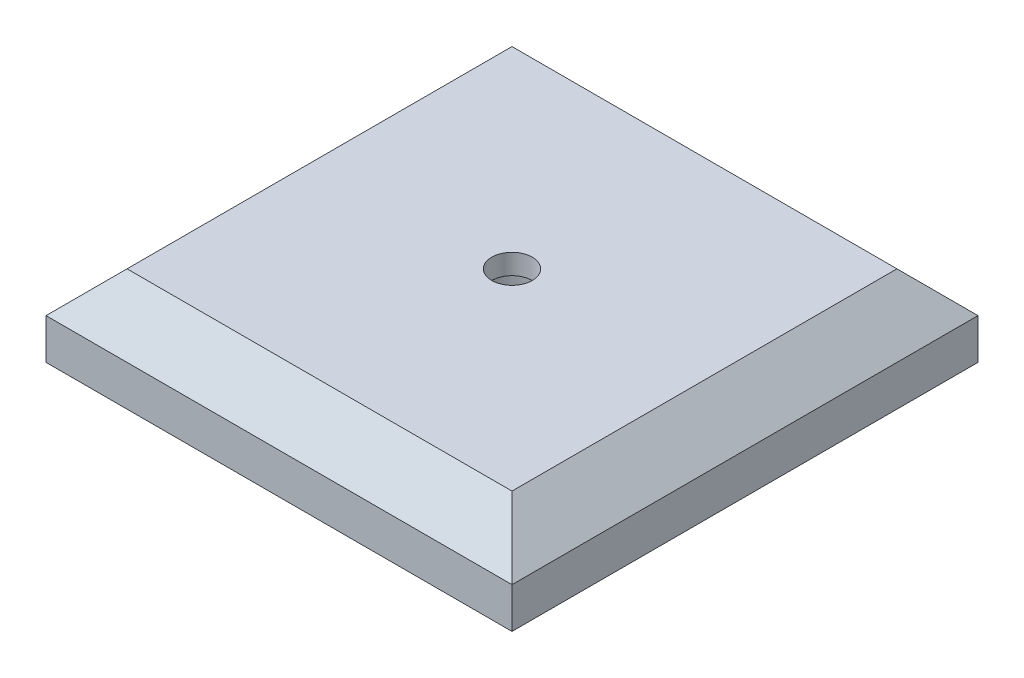
from build123d import *

# Parameters (mm, degrees)
SKETCH2_W           = 28.75
SKETCH2_H           = 28.75
BOSS_EXTRUDE1_DEPTH = 5
CHAMFER1_SIZE       = 2.5
SKETCH3_R           = 1.25
CUT_EXTRUDE1_DEPTH  = 1.25
SKETCH6_R           = 2.5
CUT_EXTRUDE2_DEPTH  = 3.75


with BuildPart() as part:
    # Sketch2 → Boss-Extrude1 (new body)
    with BuildSketch(Plane(origin=(0, 0, 0), x_dir=(1, 0, 0), z_dir=(0, 1, 0))):
        Rectangle(SKETCH2_W, SKETCH2_H)
    extrude(amount=BOSS_EXTRUDE1_DEPTH)

    # Chamfer1
    chamfer1_edges = [part.edges().sort_by_distance(p)[0] for p in [
        (-14.375, 5, 0),
        (0, 5, 14.375),
        (14.375, 5, 0),
        (0, 5, -14.375),
    ]]
    chamfer(chamfer1_edges, length=CHAMFER1_SIZE)

    # Sketch3 → Cut-Extrude1 (cut)
    with BuildSketch(Plane(origin=(0, 5, 0), x_dir=(1, 0, 0), z_dir=(0, 1, 0))):
        Circle(SKETCH3_R)
    extrude(amount=-CUT_EXTRUDE1_DEPTH, mode=Mode.SUBTRACT)

    # Sketch6 → Cut-Extrude2 (cut)
    with BuildSketch(Plane(origin=(0, 3.75, 0), x_dir=(1, 0, 0), z_dir=(0, 1, 0))):
        Circle(SKETCH6_R)
    extrude(amount=-CUT_EXTRUDE2_DEPTH, mode=Mode.SUBTRACT)


solid = part.part
